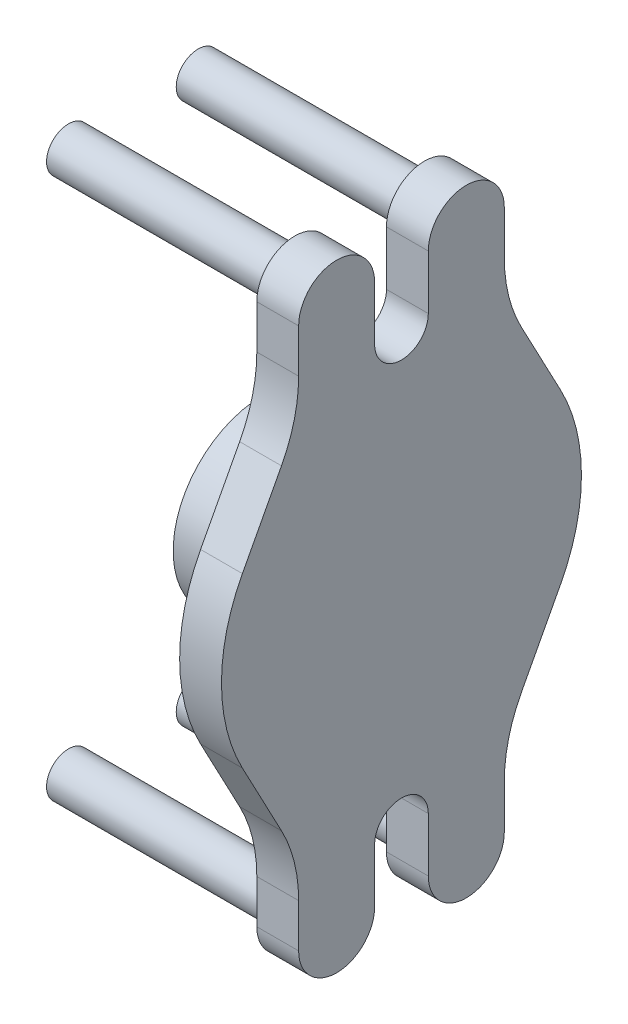
from build123d import *

# Parameters (mm, degrees)
SKETCH1_W           = 19.645
SKETCH1_H           = 18.25
SKETCH2_R           = 2.3935
CUT_EXTRUDE1_DEPTH  = 8.5725
SKETCH3_R           = 18.25
BOSS_EXTRUDE1_DEPTH = 8.5
SKETCH4_R           = 4.45
BOSS_EXTRUDE2_DEPTH = 46


with BuildPart() as part:
    # Sketch1 → Revolve1 (revolve)
    with BuildSketch(Plane.XY):
        with Locations((18.0775, 9.125)):
            Rectangle(SKETCH1_W, SKETCH1_H)
    revolve(axis=Axis((8.255, 0, 0), (1, 0, 0)))

    # Sketch2 → Cut-Extrude1 (cut)
    with BuildSketch(Plane.ZY.offset(-8.255)):
        Circle(SKETCH2_R)
    extrude(amount=-CUT_EXTRUDE1_DEPTH, mode=Mode.SUBTRACT)


with BuildPart() as body_2:
    # Sketch3 → Boss-Extrude1 (new body)
    with BuildSketch(Plane(origin=(27.9, 0, 0), x_dir=(0, 0, -1), z_dir=(1, 0, 0))):
        with BuildLine():
            Line((-24.382347836, 32.115154563), (-32.324530318, 17.115154563))
            ThreePointArc((-32.324530318, 17.115154563), (-36.576, 0), (-32.324530318, -17.115154563))
            Line((-32.324530318, -17.115154563), (-24.382347836, -32.115154563))
            ThreePointArc((-24.382347836, -32.115154563), (-21.780072988, -38.920854003), (-20.89525, -46.153175037))
            Line((-20.89525, -46.153175037), (-20.89525, -55))
            ThreePointArc((-20.89525, -55), (-13.175, -62.72025), (-5.45475, -55))
            Line((-5.45475, -55), (-5.45475, -44))
            ThreePointArc((-5.45475, -44), (0, -38.54525), (5.45475, -44))
            Line((5.45475, -44), (5.45475, -55))
            ThreePointArc((5.45475, -55), (13.175, -62.72025), (20.89525, -55))
            Line((20.89525, -55), (20.89525, -46.153175037))
            ThreePointArc((20.89525, -46.153175037), (21.780072988, -38.920854003), (24.382347836, -32.115154563))
            Line((24.382347836, -32.115154563), (32.324530318, -17.115154563))
            ThreePointArc((32.324530318, -17.115154563), (36.576, 0), (32.324530318, 17.115154563))
            Line((32.324530318, 17.115154563), (24.382347836, 32.115154563))
            ThreePointArc((24.382347836, 32.115154563), (21.780072988, 38.920854003), (20.89525, 46.153175037))
            Line((20.89525, 46.153175037), (20.89525, 55))
            ThreePointArc((20.89525, 55), (13.175, 62.72025), (5.45475, 55))
            Line((5.45475, 55), (5.45475, 44))
            ThreePointArc((5.45475, 44), (0, 38.54525), (-5.45475, 44))
            Line((-5.45475, 44), (-5.45475, 55))
            ThreePointArc((-5.45475, 55), (-13.175, 62.72025), (-20.89525, 55))
            Line((-20.89525, 55), (-20.89525, 46.153175037))
            ThreePointArc((-20.89525, 46.153175037), (-21.780072988, 38.920854003), (-24.382347836, 32.115154563))
        make_face()
        Circle(SKETCH3_R, mode=Mode.SUBTRACT)
        Circle(SKETCH3_R)
    extrude(amount=BOSS_EXTRUDE1_DEPTH)

    # Sketch4 → Boss-Extrude2 (add)
    with BuildSketch(Plane.ZY.offset(-27.9)):
        with Locations((-13.175, 55)):
            Circle(SKETCH4_R)
        with Locations((13.175, -55)):
            Circle(SKETCH4_R)
        with Locations((13.175, 55)):
            Circle(SKETCH4_R)
        with Locations((-13.175, -55)):
            Circle(SKETCH4_R)
    extrude(amount=BOSS_EXTRUDE2_DEPTH)


solid = Compound([part.part, body_2.part])
